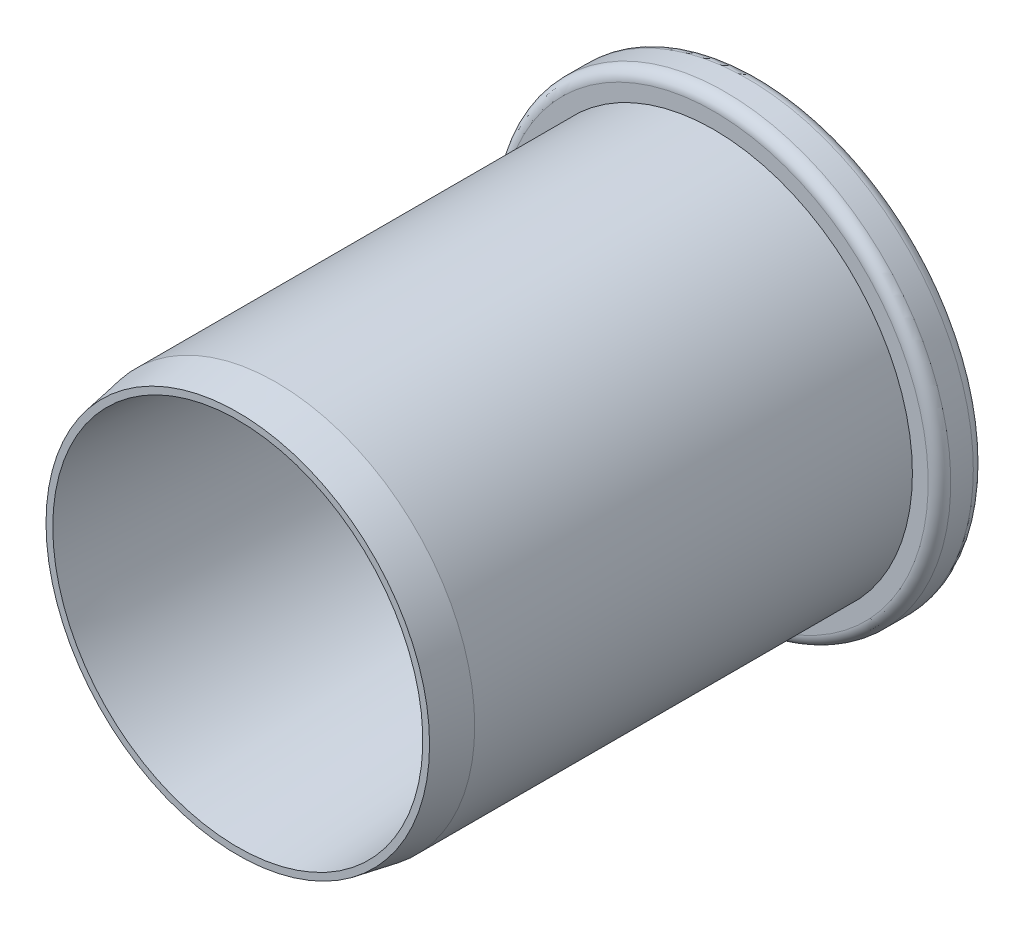
from build123d import *

# Parameters (mm, degrees)
FILLET1_R = 0.5


with BuildPart() as part:
    # Sketch1 → Revolve1 (revolve)
    with BuildSketch(Plane(origin=(0, 0, 0), x_dir=(1, 0, 0), z_dir=(0, 1, 0)), mode=Mode.PRIVATE) as revolve1_sk:
        Polygon((5, 0), (10, 0), (10, -2), (8.8, -2), (8.8, -10), (8.8, -21.398615454), (8.5, -23.1), (8.2, -23.1), (7.3, -10), (3.236730193, -10), align=None)
    revolve(revolve1_sk.sketch.rotate(Axis((0, 0, 0), (0, 0, 1)), 180), axis=Axis((0, 0, 0), (0, 0, 1)))  # turned: the seam where the file's is

    # Fillet1
    fillet1_edges = [part.edges().sort_by_distance(p)[0] for p in [
        (10, 0, 2),
        (10, 0, 0),
        (5, 0, 0),
    ]]
    fillet(fillet1_edges, radius=FILLET1_R)


solid = part.part
